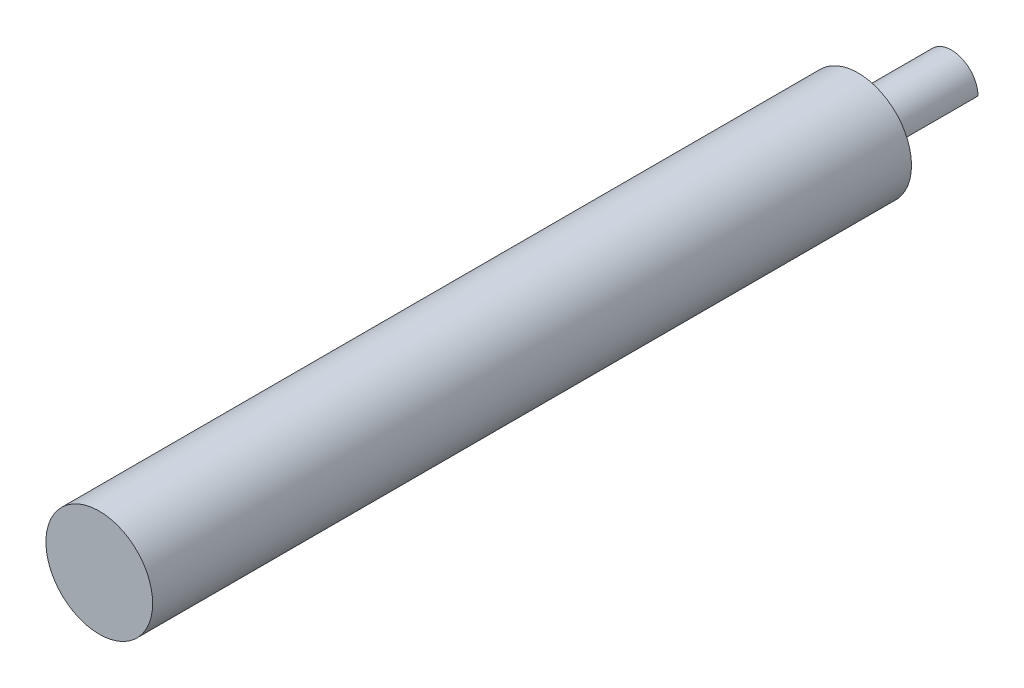
from build123d import *

# Parameters (mm, degrees)
SKETCH1_R               = 3.1623
BOSS_EXTRUDE1_DEPTH     = 11.0998
CUT_EXTRUDE1_DEPTH      = 1
CUT_EXTRUDE1_DEPTH_BACK = 12.0998
SKETCH3_R               = 6.35
BOSS_EXTRUDE2_DEPTH     = 90.297
FILLET1_R               = 1.27


with BuildPart() as part:
    # Sketch1 → Boss-Extrude1 (new body)
    with BuildSketch(Plane.XY):
        Circle(SKETCH1_R)
    extrude(amount=BOSS_EXTRUDE1_DEPTH)

    # Sketch2 → Cut-Extrude1 (cut, two sides)
    with BuildSketch(Plane(origin=(0, 0, 0), x_dir=(-1, 0, 0), z_dir=(0, 0, -1))) as cut_extrude1_sk:
        Polygon((17.073178183, -20.234228338), (0.001249598, -3.162299753), (-3.162299753, 0.001249598), (-20.234228338, 17.073178183), (-54.378085507, -17.070678986), (-17.070678986, -54.378085507), align=None)
    extrude(amount=CUT_EXTRUDE1_DEPTH, mode=Mode.SUBTRACT)
    extrude(cut_extrude1_sk.sketch, amount=-CUT_EXTRUDE1_DEPTH_BACK, mode=Mode.SUBTRACT)

    # Sketch3 → Boss-Extrude2 (add)
    with BuildSketch(Plane.XY.offset(11.0998)):
        Circle(SKETCH3_R)
    extrude(amount=BOSS_EXTRUDE2_DEPTH)

    # Fillet1
    fillet1_edges = [part.edges().sort_by_distance(p)[0] for p in [
        (-2.236083774, 2.236083774, 11.0998),
        (1.580525077, -1.580525077, 11.0998),
    ]]
    fillet(fillet1_edges, radius=FILLET1_R)


solid = part.part
